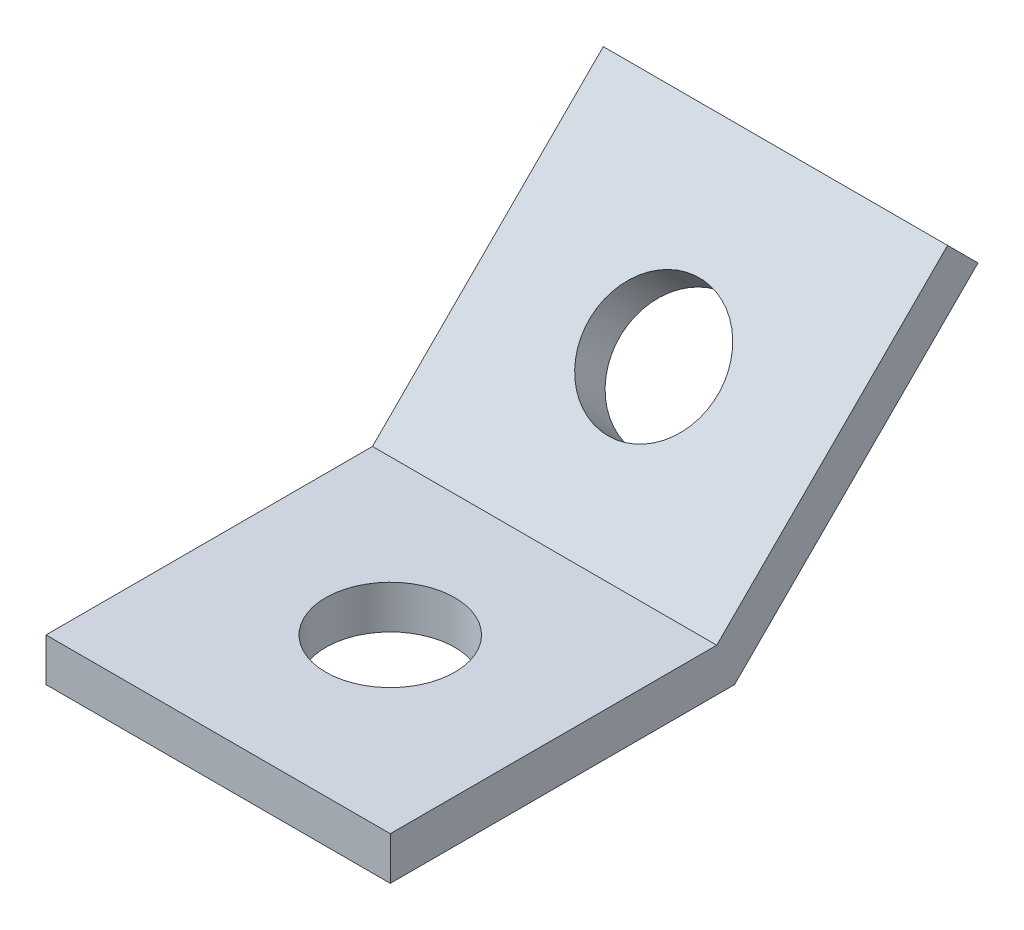
from build123d import *

# Parameters (mm, degrees)
BOSS_EXTRUDE1_DEPTH = 25.4
SKETCH2_R           = 4.7625
CUT_EXTRUDE1_DEPTH  = 25.4
SKETCH3_R           = 4.7625
CUT_EXTRUDE2_DEPTH  = 16.875


with BuildPart() as part:
    # Sketch1 → Boss-Extrude1 (new body)
    with BuildSketch(Plane(origin=(0, 0, 0), x_dir=(0, 0, -1), z_dir=(1, 0, 0))):
        Polygon((0, 0), (-25.4, 0), (-25.4, 3.175), (-1.315128061, 3.175), (15.715448212, 20.205576272), (17.960512242, 17.960512242), align=None)
    extrude(amount=BOSS_EXTRUDE1_DEPTH)

    # Sketch2 → Cut-Extrude1 (cut)
    with BuildSketch(Plane(origin=(0, 3.175, 0), x_dir=(1, 0, 0), z_dir=(0, 1, 0))):
        with Locations((12.7, -12.7)):
            Circle(SKETCH2_R)
    extrude(amount=-CUT_EXTRUDE1_DEPTH, mode=Mode.SUBTRACT)

    # Sketch3 → Cut-Extrude2 (cut, through all)
    with BuildSketch(Plane(origin=(0, 2.24506403, 2.24506403), x_dir=(1, 0, 0), z_dir=(0, 0.707106781, 0.707106781))):
        with Locations((12.7, 12.7)):
            Circle(SKETCH3_R)
    extrude(amount=-CUT_EXTRUDE2_DEPTH, mode=Mode.SUBTRACT)


solid = part.part
